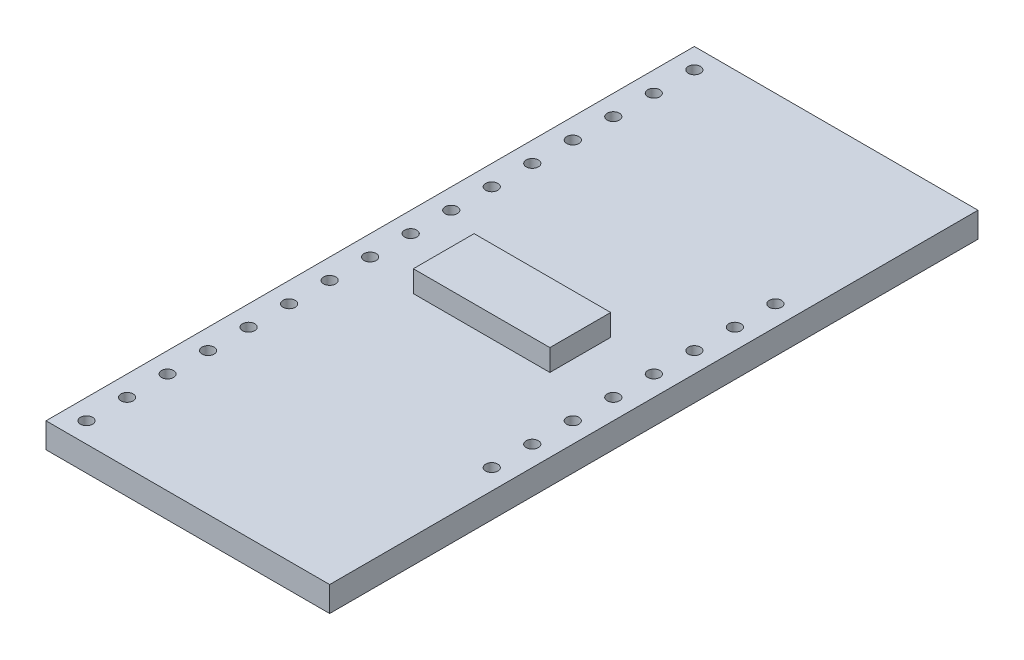
from build123d import *

# Parameters (mm, degrees)
SKETCH1_W                 = 17.78
SKETCH1_H                 = 40.64
PCB_DEPTH                 = 1.5748
SKETCH2_R                 = 0.381
HOLE_PATTERN_SEED_1_DEPTH = 1.5748
HP_1X16_COUNT             = 16
HP_1X16_PITCH             = 2.54
SKETCH3_R                 = 0.381
HOLE_PATTERN_SEED_2_DEPTH = 1.5748
HP_1X08_COUNT             = 8
HP_1X08_PITCH             = 2.54
SKETCH4_W                 = 8.5598
SKETCH4_H                 = 3.81
SSOP_24_DEPTH             = 1.35128


with BuildPart() as part:
    # Sketch1 → PCB (new body)
    with BuildSketch(Plane(origin=(0, 0, 0), x_dir=(1, 0, 0), z_dir=(0, 1, 0))):
        with Locations((8.89, 20.32)):
            Rectangle(SKETCH1_W, SKETCH1_H)
    extrude(amount=PCB_DEPTH)

    # Sketch2 → Hole Pattern seed 1 (cut)
    with BuildSketch(Plane(origin=(0, 1.5748, 0), x_dir=(1, 0, 0), z_dir=(0, 1, 0))):
        with Locations((1.27, 1.27)):
            Circle(SKETCH2_R)
    hole_pattern_seed_1 = extrude(amount=-HOLE_PATTERN_SEED_1_DEPTH, mode=Mode.SUBTRACT)

    # HP 1x16: Hole Pattern seed 1 ×16
    with Locations(*[(0, 0, -i * HP_1X16_PITCH) for i in range(1, HP_1X16_COUNT)]):
        add(hole_pattern_seed_1, mode=Mode.SUBTRACT)

    # Sketch3 → Hole Pattern seed 2 (cut)
    with BuildSketch(Plane(origin=(0, 1.5748, 0), x_dir=(1, 0, 0), z_dir=(0, 1, 0))):
        with Locations((16.51, 11.43)):
            Circle(SKETCH3_R)
    hole_pattern_seed_2 = extrude(amount=-HOLE_PATTERN_SEED_2_DEPTH, mode=Mode.SUBTRACT)

    # HP 1x08: Hole Pattern seed 2 ×8
    with Locations(*[(0, 0, -i * HP_1X08_PITCH) for i in range(1, HP_1X08_COUNT)]):
        add(hole_pattern_seed_2, mode=Mode.SUBTRACT)

    # Sketch4 → SSOP-24 (add)
    with BuildSketch(Plane(origin=(0, 1.5748, 0), x_dir=(1, 0, 0), z_dir=(0, 1, 0))):
        with Locations((8.89, 20.32)):
            Rectangle(SKETCH4_W, SKETCH4_H)
    extrude(amount=SSOP_24_DEPTH)


solid = part.part
